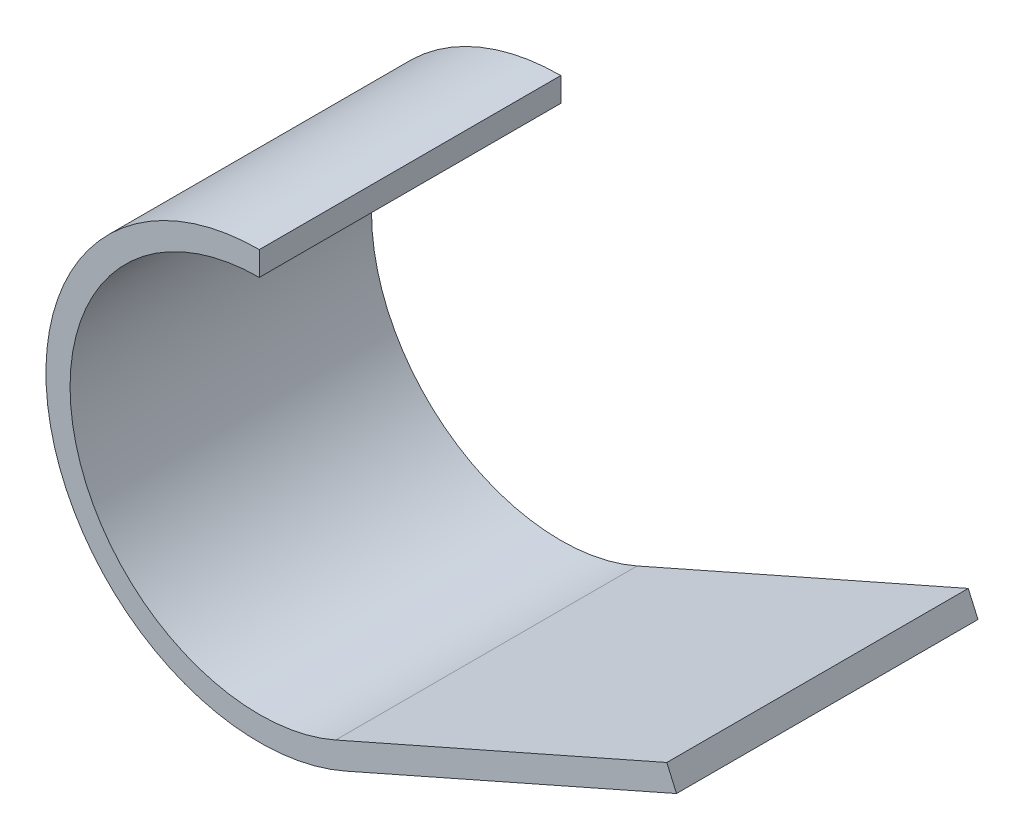
from build123d import *

# Parameters (mm, degrees)
EXTRUDE_THIN1_DEPTH = 25


with BuildPart() as part:
    # Sketch1 → Extrude-Thin1 (new body)
    with BuildSketch(Plane.XY):
        with BuildLine():
            Line((24.741809676, -2.24523669), (-2.711887908, -14.358741432))
            ThreePointArc((-2.711887908, -14.358741432), (-24.404276202, -3.237408341), (-9.047452794, 15.694356882))
            Line((-9.047452794, 15.694356882), (-9.047452794, 17.694356882))
            ThreePointArc((-9.047452794, 17.694356882), (-26.361262847, -3.649965334), (-1.904519382, -16.18853816))
            Line((-1.904519382, -16.18853816), (25.549178202, -4.075033418))
            Line((25.549178202, -4.075033418), (24.741809676, -2.24523669))
        make_face()
    extrude(amount=EXTRUDE_THIN1_DEPTH)


solid = part.part
